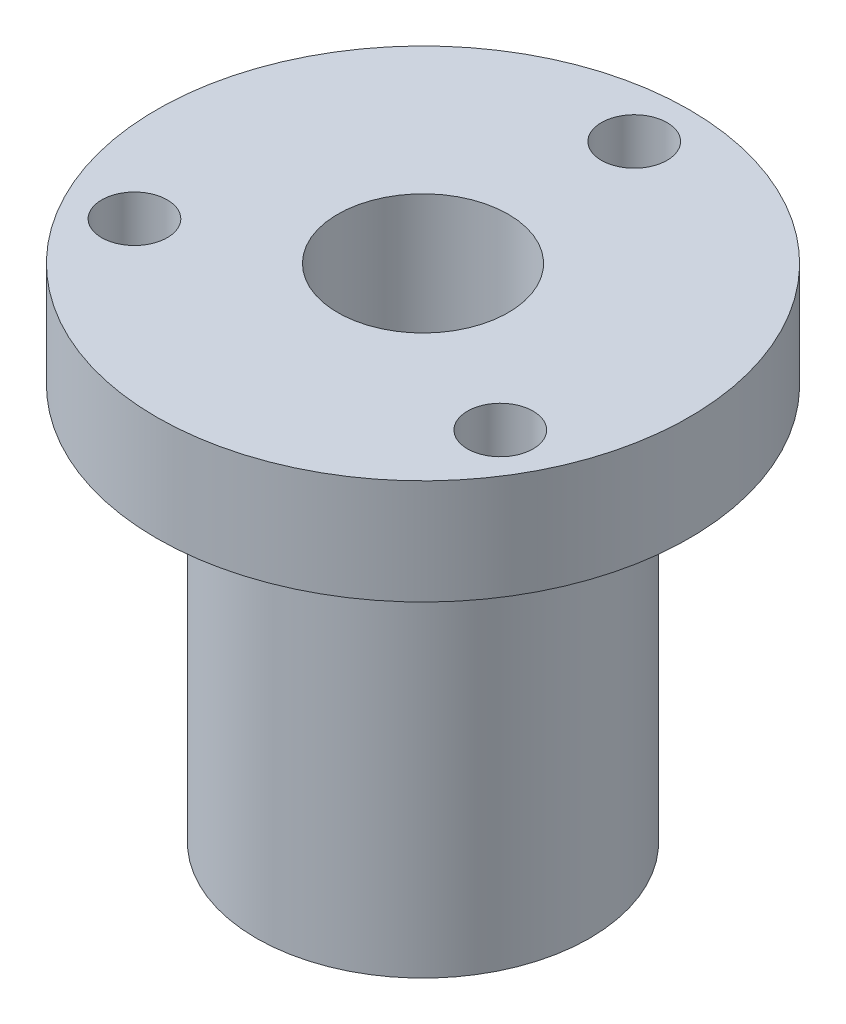
from build123d import *

# Parameters (mm, degrees)
CORTAR_EXTRUIR1_REACH     = 21.1
CROQUIS2_R                = 1.25
TALADRO_ROSCADO_M31_D     = 2.5
TALADRO_ROSCADO_M31_DEPTH = 8.5
TALADRO_ROSCADO_M31_TIP   = 0.751075774


with BuildPart() as part:
    # Croquis1 → Revolución1 (revolve)
    with BuildSketch(Plane.XY):
        Polygon((6.35, 0), (6.35, 15.1), (10.15, 15.1), (10.15, 19.1), (3.25, 19.1), (3.25, 0), align=None)
    revolve(axis=Axis((0, 0, 0), (0, 1, 0)))

    # Croquis2 → Cortar-Extruir1 (cut, up to next)
    with BuildSketch(Plane(origin=(0, 19.1, 0), x_dir=(1, 0, 0), z_dir=(0, 1, 0)), mode=Mode.PRIVATE) as cortar_extruir1_sk1:
        with Locations((6.9715045, -4.025)):
            Circle(CROQUIS2_R)
    cortar_extruir1_tool1 = extrude(cortar_extruir1_sk1.sketch, amount=-CORTAR_EXTRUIR1_REACH, mode=Mode.PRIVATE) & part.part
    add(cortar_extruir1_tool1.solids().sort_by_distance((6.971505, 19.1, 4.025))[0], mode=Mode.SUBTRACT)
    # Croquis2 → Cortar-Extruir1 (cut, up to next)
    with BuildSketch(Plane(origin=(0, 19.1, 0), x_dir=(1, 0, 0), z_dir=(0, 1, 0)), mode=Mode.PRIVATE) as cortar_extruir1_sk2:
        with Locations((0, 8.05)):
            Circle(CROQUIS2_R)
    cortar_extruir1_tool2 = extrude(cortar_extruir1_sk2.sketch, amount=-CORTAR_EXTRUIR1_REACH, mode=Mode.PRIVATE) & part.part
    add(cortar_extruir1_tool2.solids().sort_by_distance((0, 19.1, -8.05))[0], mode=Mode.SUBTRACT)
    # Croquis2 → Cortar-Extruir1 (cut, up to next)
    with BuildSketch(Plane(origin=(0, 19.1, 0), x_dir=(1, 0, 0), z_dir=(0, 1, 0)), mode=Mode.PRIVATE) as cortar_extruir1_sk3:
        with Locations((-6.9715045, -4.025)):
            Circle(CROQUIS2_R)
    cortar_extruir1_tool3 = extrude(cortar_extruir1_sk3.sketch, amount=-CORTAR_EXTRUIR1_REACH, mode=Mode.PRIVATE) & part.part
    add(cortar_extruir1_tool3.solids().sort_by_distance((-6.971505, 19.1, 4.025))[0], mode=Mode.SUBTRACT)

    # Taladro roscado M31
    with Locations(Plane(origin=(0, 15.1, -8.05), x_dir=(0, 0, -1), z_dir=(0, -1, 0))):
        with Locations((0, 0), (-12.075, 6.9715045), (-12.075, -6.9715045)):
            Hole(TALADRO_ROSCADO_M31_D / 2, depth=TALADRO_ROSCADO_M31_DEPTH)
            with Locations((0, 0, -(TALADRO_ROSCADO_M31_DEPTH + TALADRO_ROSCADO_M31_TIP / 2))):  # 118° drill point
                Cone(0, TALADRO_ROSCADO_M31_D / 2, TALADRO_ROSCADO_M31_TIP, mode=Mode.SUBTRACT)


solid = part.part
